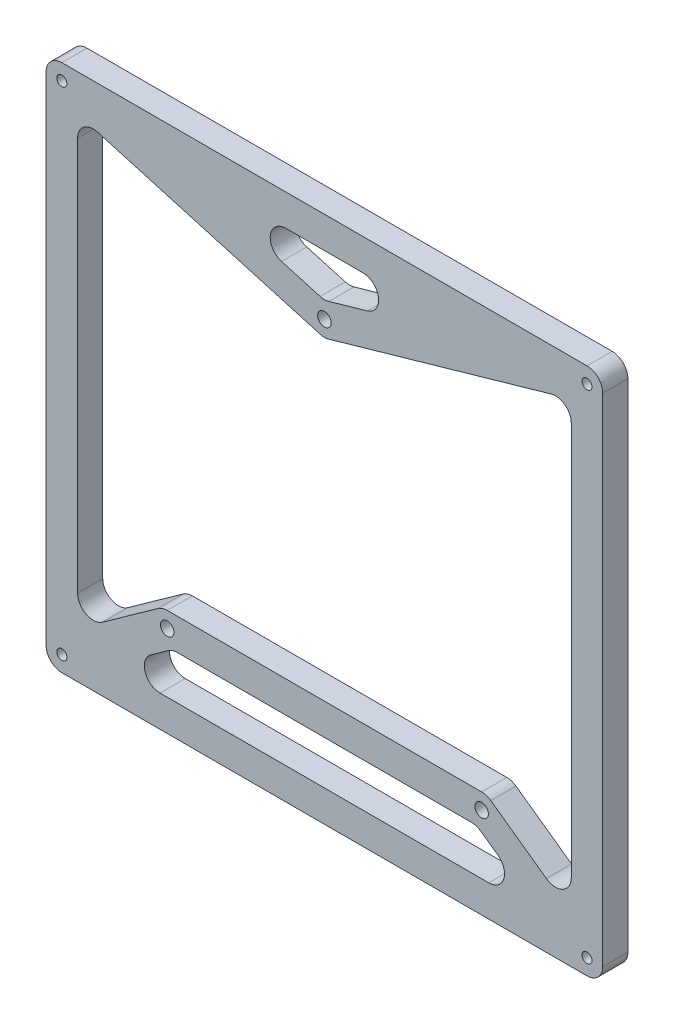
from build123d import *

# Parameters (mm, degrees)
BOSS_EXTRU_1_DEPTH = 8
D_GAGEMENT_M31_D   = 3.2
D_GAGEMENT_M41_D   = 4.3


with BuildPart() as part:
    # Esquisse1 → Boss.-Extru.1 (new body)
    with BuildSketch(Plane.XY):
        with BuildLine():
            Line((-83.5, -84), (83.5, -84))
            ThreePointArc((83.5, -84), (87.035533906, -82.535533906), (88.5, -79))
            Line((88.5, -79), (88.5, 79))
            ThreePointArc((88.5, 79), (87.035533906, 82.535533906), (83.5, 84))
            Line((83.5, 84), (-83.5, 84))
            ThreePointArc((-83.5, 84), (-87.035533906, 82.535533906), (-88.5, 79))
            Line((-88.5, 79), (-88.5, -79))
            ThreePointArc((-88.5, -79), (-87.035533906, -82.535533906), (-83.5, -84))
        make_face()
        with BuildLine():
            Line((-52.904447079, -51.023190589), (-70.595552921, -63.648248646))
            ThreePointArc((-70.595552921, -63.648248646), (-75.788860481, -64.02368409), (-78.5, -59.578336218))
            Line((-78.5, -59.578336218), (-78.5, 65.735103055))
            ThreePointArc((-78.5, 65.735103055), (-76.509878124, 69.727675368), (-72.123746529, 70.541965481))
            Line((-72.123746529, 70.541965481), (-1.376253471, 50.286240591))
            ThreePointArc((-1.376253471, 50.286240591), (0, 50.093103017), (1.376253471, 50.286240591))
            Line((1.376253471, 50.286240591), (72.123746529, 70.541965481))
            ThreePointArc((72.123746529, 70.541965481), (76.509878124, 69.727675368), (78.5, 65.735103055))
            Line((78.5, 65.735103055), (78.5, -59.578336218))
            ThreePointArc((78.5, -59.578336218), (75.788860481, -64.02368409), (70.595552921, -63.648248646))
            Line((70.595552921, -63.648248646), (52.904447079, -51.023190589))
            ThreePointArc((52.904447079, -51.023190589), (51.524866857, -50.331298625), (50, -50.093103017))
            Line((50, -50.093103017), (-50, -50.093103017))
            ThreePointArc((-50, -50.093103017), (-51.524866857, -50.331298625), (-52.904447079, -51.023190589))
        make_face(mode=Mode.SUBTRACT)
        with BuildLine():
            Line((-49.702159182, -61.023190589), (-55.176773853, -64.930087573))
            ThreePointArc((-55.176773853, -64.930087573), (-57.034131166, -70.524866857), (-52.272326774, -74))
            Line((-52.272326774, -74), (52.272326774, -74))
            ThreePointArc((52.272326774, -74), (57.034131166, -70.524866857), (55.176773853, -64.930087573))
            Line((55.176773853, -64.930087573), (49.702159182, -61.023190589))
            ThreePointArc((49.702159182, -61.023190589), (48.322578961, -60.331298625), (46.797712104, -60.093103017))
            Line((46.797712104, -60.093103017), (-46.797712104, -60.093103017))
            ThreePointArc((-46.797712104, -60.093103017), (-48.322578961, -60.331298625), (-49.702159182, -61.023190589))
        make_face(mode=Mode.SUBTRACT)
        with BuildLine():
            Line((-13.618577234, 64.193137574), (-1.376253471, 60.6880361))
            ThreePointArc((-1.376253471, 60.6880361), (0, 60.494898526), (1.376253471, 60.6880361))
            Line((1.376253471, 60.6880361), (13.618577234, 64.193137574))
            ThreePointArc((13.618577234, 64.193137574), (17.193803952, 69.694869725), (12.242323763, 74))
            Line((12.242323763, 74), (-12.242323763, 74))
            ThreePointArc((-12.242323763, 74), (-17.193803952, 69.694869725), (-13.618577234, 64.193137574))
        make_face(mode=Mode.SUBTRACT)
    extrude(amount=BOSS_EXTRU_1_DEPTH)

    # Dégagement M31 (through all)
    with Locations(Plane.XY.offset(8)):
        with Locations((-83.5, 79), (-83.5, -79), (83.5, -79), (83.5, 79)):
            Hole(D_GAGEMENT_M31_D / 2)

    # Dégagement M41 (through all)
    with Locations(Plane.XY.offset(8)):
        with Locations((-50, -55.093103017), (50, -55.093103017), (0, 55.093103017)):
            Hole(D_GAGEMENT_M41_D / 2)


solid = part.part
